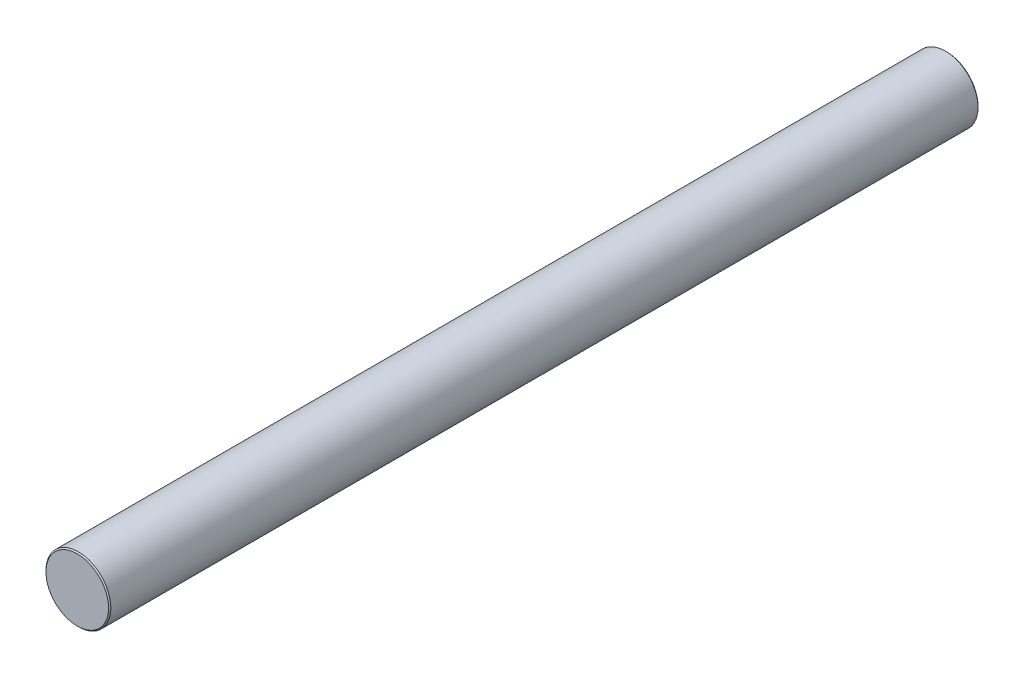
from build123d import *

# Parameters (mm, degrees)
SKETCH1_R           = 28
BOSS_EXTRUDE1_DEPTH = 375
CHAMFER1_SIZE       = 1


with BuildPart() as part:
    # Sketch1 → Boss-Extrude1 (new body, symmetric)
    with BuildSketch(Plane.XY):
        Circle(SKETCH1_R)
    extrude(amount=BOSS_EXTRUDE1_DEPTH, both=True)

    # Chamfer1
    chamfer1_edges = [part.edges().sort_by_distance(p)[0] for p in [
        (-28, 0, -375),
        (-28, 0, 375),
    ]]
    chamfer(chamfer1_edges, length=CHAMFER1_SIZE)


solid = part.part
